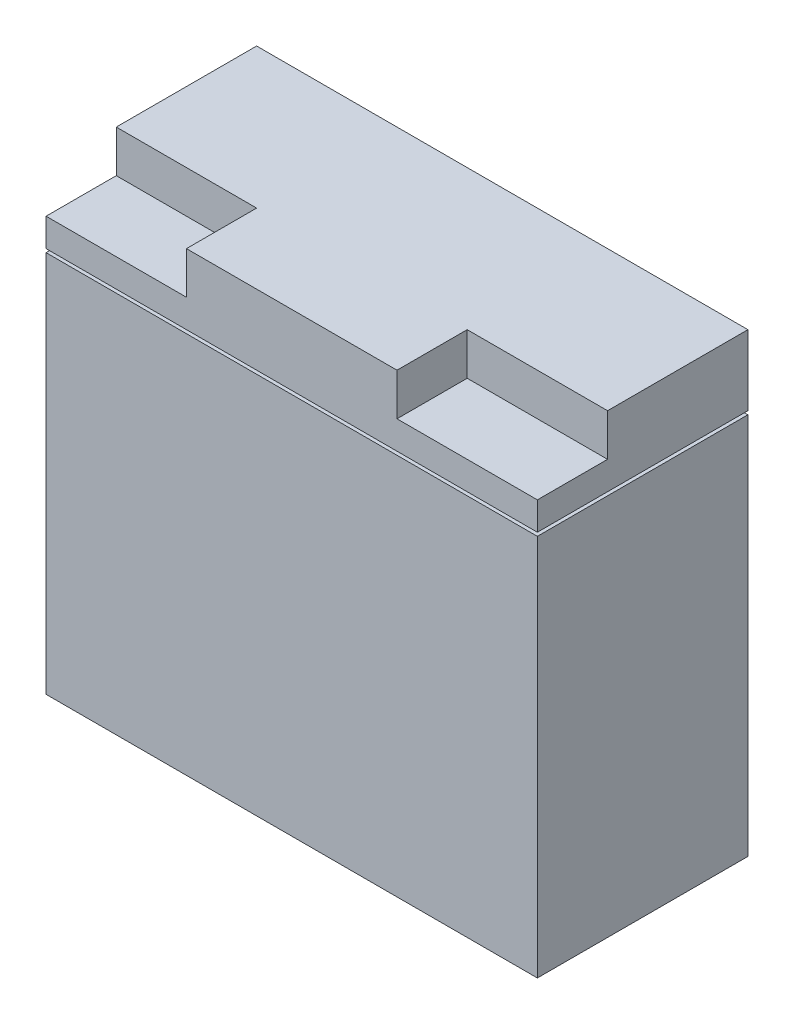
from build123d import *

# Parameters (mm, degrees)
SKETCH1_W           = 177.8
SKETCH1_H           = 76.2
BOSS_EXTRUDE1_DEPTH = 165.1
SKETCH2_W           = 50.8
SKETCH2_H           = 25.4
CUT_EXTRUDE1_DEPTH  = 15.24
SKETCH3_W           = 177.8
SKETCH3_H           = 76.2
SKETCH3_W_2         = 175.26
SKETCH3_H_2         = 73.66
CUT_EXTRUDE2_DEPTH  = 1.27


with BuildPart() as part:
    # Sketch1 → Boss-Extrude1 (new body)
    with BuildSketch(Plane(origin=(0, 0, 0), x_dir=(1, 0, 0), z_dir=(0, 1, 0))):
        with Locations((88.9, 38.1)):
            Rectangle(SKETCH1_W, SKETCH1_H)
    extrude(amount=BOSS_EXTRUDE1_DEPTH)

    # Sketch2 → Cut-Extrude1 (cut)
    with BuildSketch(Plane(origin=(0, 165.1, 0), x_dir=(1, 0, 0), z_dir=(0, 1, 0))):
        with Locations((25.4, 12.7)):
            Rectangle(SKETCH2_W, SKETCH2_H)
        with Locations((152.4, 12.7)):
            Rectangle(SKETCH2_W, SKETCH2_H)
    extrude(amount=-CUT_EXTRUDE1_DEPTH, mode=Mode.SUBTRACT)

    # Sketch3 → Cut-Extrude2 (cut)
    with BuildSketch(Plane(origin=(0, 139.7, 0), x_dir=(1, 0, 0), z_dir=(0, 1, 0))):
        with Locations((88.9, 38.1)):
            Rectangle(SKETCH3_W, SKETCH3_H)
        with Locations((88.9, 38.1)):
            Rectangle(SKETCH3_W_2, SKETCH3_H_2, mode=Mode.SUBTRACT)
    extrude(amount=-CUT_EXTRUDE2_DEPTH, mode=Mode.SUBTRACT)


solid = part.part
